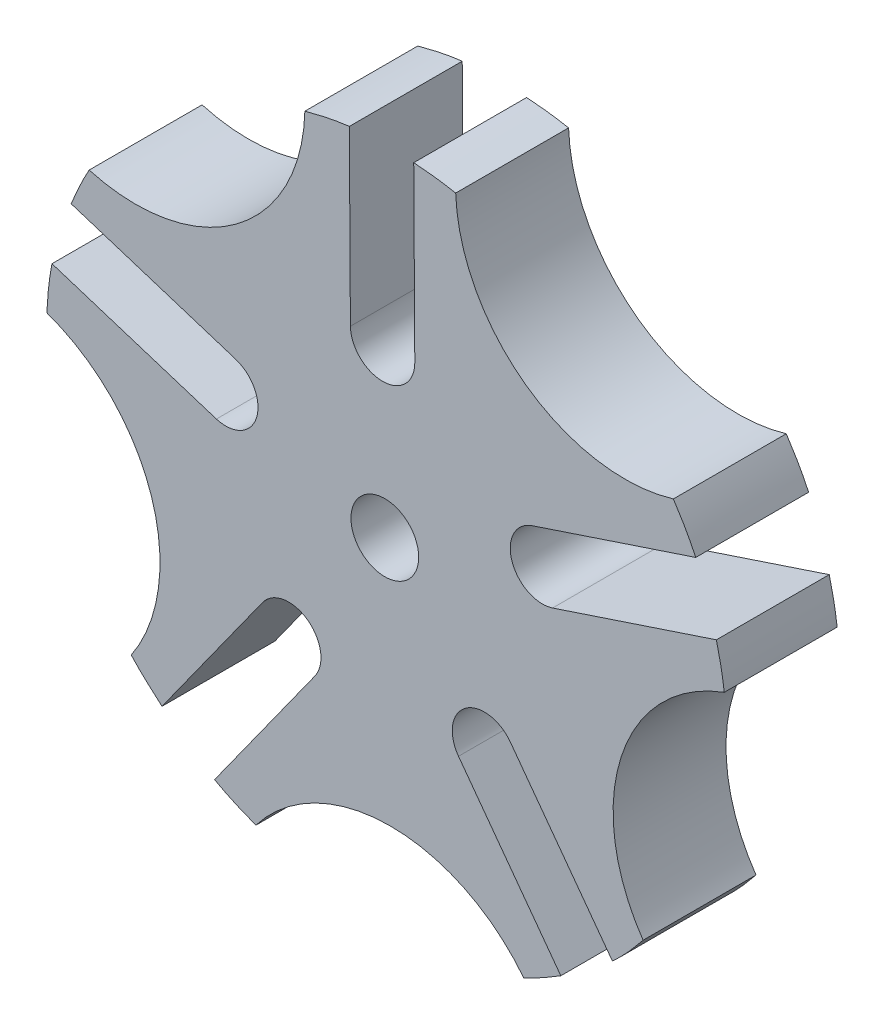
from build123d import *

# Parameters (mm, degrees)
MODEL_R                 = 3
BOSS_EXTRUDE3_DEPTH     = 10
CUT_EXTRUDE1_DEPTH      = 3
CUT_EXTRUDE1_DEPTH_BACK = 3


with BuildPart() as part:
    # Model → Boss-Extrude3 (new body)
    with BuildSketch(Plane.XY):
        with BuildLine():
            add(Edge.make_bspline(
                [(-27.783884398, 11.720720152), (-27.312273784, 12.880782387), (-26.795019787, 14.018174114), (-26.185754442, 15.108459083)],
                knots=[0.852290179, 0.852290179, 0.852290179, 0.852290179, 0.87243197, 0.87243197, 0.87243197, 0.87243197], degree=3))
            ThreePointArc((-26.185754442, 15.108459083), (-13.183686547, 17.45567821), (-7.081525862, 29.174331808))
            add(Edge.make_bspline(
                [(-7.081525862, 29.174331808), (-5.777480255, 29.53777265), (-4.469238519, 29.818781923), (-3.142641746, 29.977736074)],
                knots=[0, 0, 0, 0, 0.021616293, 0.021616293, 0.021616293, 0.021616293], degree=3))
            Line((-3.142641746, 29.977736074), (-3.047607508, 14.694279391))
            ThreePointArc((-3.047607508, 14.694279391), (-0.161689439, 11.892698747), (2.656409066, 14.762489335))
            Line((2.656409066, 14.762489335), (2.561374827, 30.045946018))
            add(Edge.make_bspline(
                [(2.561374827, 30.045946018), (3.81039527, 29.955896616), (5.051959359, 29.815432204), (6.277155329, 29.572903012)],
                knots=[0.052290179, 0.052290179, 0.052290179, 0.052290179, 0.07243197, 0.07243197, 0.07243197, 0.07243197], degree=3))
            ThreePointArc((6.277155329, 29.572903012), (12.527353316, 17.932532214), (25.558126537, 15.750295644))
            add(Edge.make_bspline(
                [(25.558126537, 15.750295644), (26.306751572, 14.62238397), (26.978276202, 13.465008783), (27.53939153, 12.252459811)],
                knots=[0.2, 0.2, 0.2, 0.2, 0.221616293, 0.221616293, 0.221616293, 0.221616293], degree=3))
            Line((27.53939153, 12.252459811), (13.033327655, 7.439229031))
            ThreePointArc((13.033327655, 7.439229031), (11.260663856, 3.828821816), (14.860837224, 2.035464932))
            Line((14.860837224, 2.035464932), (29.366901099, 6.848695711))
            add(Edge.make_bspline(
                [(29.366901099, 6.848695711), (29.667227572, 5.632979885), (29.91730238, 4.408776378), (30.065249788, 3.168600124)],
                knots=[0.252290179, 0.252290179, 0.252290179, 0.252290179, 0.27243197, 0.27243197, 0.27243197, 0.27243197], degree=3))
            ThreePointArc((30.065249788, 3.168600124), (20.926016685, -6.372763797), (22.87731675, -19.440113767))
            add(Edge.make_bspline(
                [(22.87731675, -19.440113767), (22.03594686, -20.50064236), (21.14273017, -21.496948837), (20.162921741, -22.405299465)],
                knots=[0.4, 0.4, 0.4, 0.4, 0.421616293, 0.421616293, 0.421616293, 0.421616293], degree=3))
            Line((20.162921741, -22.405299465), (11.102646985, -10.096582999))
            ThreePointArc((11.102646985, -10.096582999), (7.121162438, -9.526356728), (6.52809344, -13.504502824))
            Line((6.52809344, -13.504502824), (15.588368196, -25.81321929))
            add(Edge.make_bspline(
                [(15.588368196, -25.81321929), (14.524959722, -26.474523589), (13.437950364, -27.090658554), (12.30419092, -27.614600438)],
                knots=[0.452290179, 0.452290179, 0.452290179, 0.452290179, 0.47243197, 0.47243197, 0.47243197, 0.47243197], degree=3))
            ThreePointArc((12.30419092, -27.614600438), (0.405636244, -21.871116843), (-11.419167214, -27.764946697))
            add(Edge.make_bspline(
                [(-11.419167214, -27.764946697), (-12.687787438, -27.292477739), (-13.911350342, -26.750853818), (-15.078020581, -26.099696408)],
                knots=[0.6, 0.6, 0.6, 0.6, 0.621616293, 0.621616293, 0.621616293, 0.621616293], degree=3))
            Line((-15.078020581, -26.099696408), (-6.171514453, -13.679260495))
            ThreePointArc((-6.171514453, -13.679260495), (-6.85954343, -9.716434063), (-10.826253597, -10.381706678))
            Line((-10.826253597, -10.381706678), (-19.732759725, -22.802142592))
            add(Edge.make_bspline(
                [(-19.732759725, -22.802142592), (-20.690308779, -21.995135299), (-21.612192316, -21.151724141), (-22.460841595, -20.235361781)],
                knots=[0.652290179, 0.652290179, 0.652290179, 0.652290179, 0.67243197, 0.67243197, 0.67243197, 0.67243197], degree=3))
            ThreePointArc((-22.460841595, -20.235361781), (-20.675319699, -7.144329784), (-29.934750212, 2.280433012))
            add(Edge.make_bspline(
                [(-29.934750212, 2.280433012), (-29.877430739, 3.63296348), (-29.740417511, 4.964011949), (-29.481650943, 6.274799988)],
                knots=[0.8, 0.8, 0.8, 0.8, 0.821616293, 0.821616293, 0.821616293, 0.821616293], degree=3))
            Line((-29.481650943, 6.274799988), (-14.916852679, 1.642335072))
            ThreePointArc((-14.916852679, 1.642335072), (-11.360593424, 3.521270227), (-13.219086134, 7.088255236))
            Line((-13.219086134, 7.088255236), (-27.783884398, 11.720720152))
        make_face()
        Circle(MODEL_R, mode=Mode.SUBTRACT)
    extrude(amount=BOSS_EXTRUDE3_DEPTH)

    # Sketch2 → Cut-Extrude1 (cut, two sides)
    with BuildSketch(Plane.XY) as cut_extrude1_sk:
        Polygon((-2.402263966, 4.270729193), (-4.899691957, 0.054942975), (-2.497427991, -4.215786218), (2.402263966, -4.270729193), (4.899691957, -0.054942975), (2.497427991, 4.215786218), align=None)
    extrude(amount=CUT_EXTRUDE1_DEPTH, mode=Mode.SUBTRACT)
    extrude(cut_extrude1_sk.sketch, amount=-CUT_EXTRUDE1_DEPTH_BACK, mode=Mode.SUBTRACT)


solid = part.part
